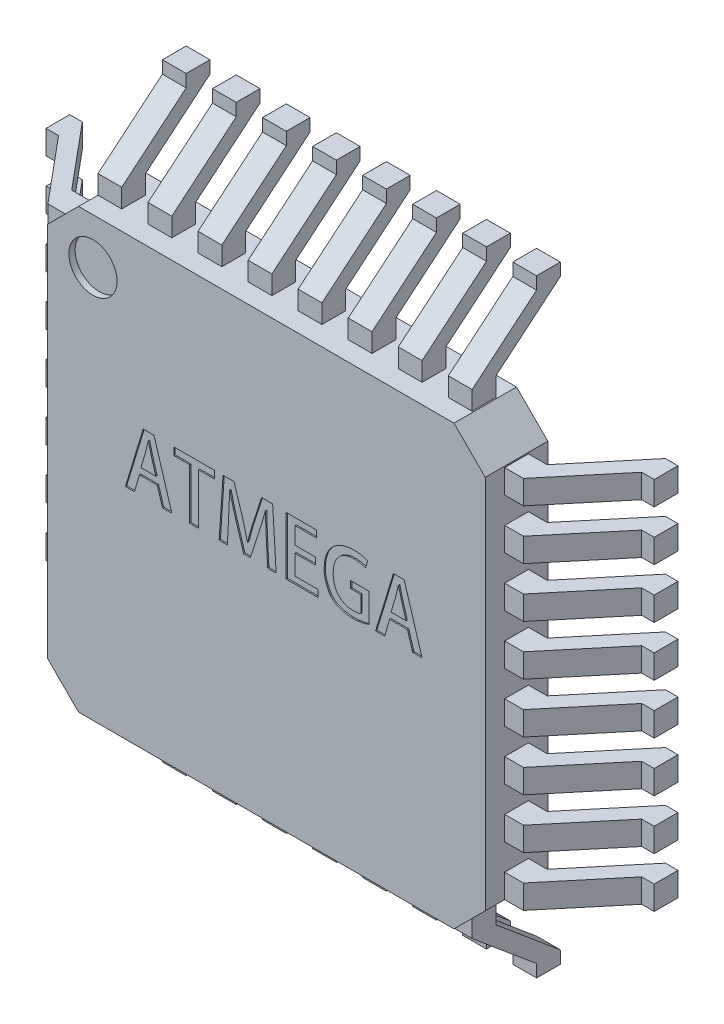
from build123d import *

# Parameters (mm, degrees)
CORPS_DEPTH                = 1
ESQUISSE2_R                = 0.385
ENL_V_MAT_EXTRU_1_DEPTH    = 0.1
TEXTE_DEPTH                = 0.02
PATTE_DEPTH                = 0.38
R_P_TITION_LIN_AIRE1_COUNT = 8
R_P_TITION_LIN_AIRE1_PITCH = 0.8
SYM_TRIE1_COPY_1_DEPTH     = 0.38
SYM_TRIE1_COPY_2_DEPTH     = 0.38
SYM_TRIE1_COPY_3_DEPTH     = 0.38
SYM_TRIE1_COPY_4_DEPTH     = 0.38
SYM_TRIE1_COPY_5_DEPTH     = 0.38
SYM_TRIE1_COPY_6_DEPTH     = 0.38
SYM_TRIE1_COPY_7_DEPTH     = 0.38
BOSS_EXTRU_3_DEPTH         = 0.38
R_P_TITION_LIN_AIRE2_COUNT = 8
R_P_TITION_LIN_AIRE2_PITCH = 0.8
SYM_TRIE2_COPY_1_DEPTH     = 0.38
SYM_TRIE2_COPY_2_DEPTH     = 0.38
SYM_TRIE2_COPY_3_DEPTH     = 0.38
SYM_TRIE2_COPY_4_DEPTH     = 0.38
SYM_TRIE2_COPY_5_DEPTH     = 0.38
SYM_TRIE2_COPY_6_DEPTH     = 0.38
SYM_TRIE2_COPY_7_DEPTH     = 0.38


with BuildPart() as part:
    # Esquisse1 → Corps (new body)
    with BuildSketch(Plane.XY):
        Polygon((-3.5, 3), (-3, 3.5), (3, 3.5), (3.5, 3), (3.5, -3), (3, -3.5), (-3, -3.5), (-3.5, -3), align=None)
    extrude(amount=CORPS_DEPTH)

    # Esquisse2 → Enlèv. mat.-Extru.1 (cut)
    with BuildSketch(Plane.XY.offset(1)):
        with Locations((-2.77, 2.77)):
            Circle(ESQUISSE2_R)
    extrude(amount=-ENL_V_MAT_EXTRU_1_DEPTH, mode=Mode.SUBTRACT)

    # Esquisse3 → Texte (cut)
    with BuildSketch(Plane.XY.offset(1)):
        Polygon((-1.793941796, 0.933727574), (-1.96665398, 0.933727574), (-2.251300977, -0.002415723), (-2.106526523, -0.002415723), (-2.026251846, 0.271286617), (-1.741641628, 0.271286617), (-1.657718102, -0.002415723), (-1.509331578, -0.002415723), align=None)
        with BuildLine():
            Line((-2.004358752, 0.381984009), (-1.93016549, 0.628287758))
            add(Edge.make_bspline(
                [(-1.93016549, 0.628287758), (-1.926197376, 0.643224093), (-1.918096873, 0.673715101), (-1.907409013, 0.720118537), (-1.896836875, 0.766426537), (-1.889875841, 0.79705332), (-1.886475719, 0.812012999)],
                knots=[0, 0, 0, 0, 0.981880665, 2.004409445, 3.025252049, 4, 4, 4, 4], degree=3))
            Line((-1.886475719, 0.812012999), (-1.883946737, 0.812082089))
            add(Edge.make_bspline(
                [(-1.883946737, 0.812082089), (-1.880536217, 0.797210544), (-1.87355085, 0.7667509), (-1.862387649, 0.720611295), (-1.850566242, 0.673771581), (-1.84211295, 0.642582439), (-1.837902769, 0.627048617)],
                knots=[0, 0, 0, 0, 0.960134074, 1.966530216, 2.987225846, 4, 4, 4, 4], degree=3))
            Line((-1.837902769, 0.627048617), (-1.764751004, 0.381984009))
            Line((-1.764751004, 0.381984009), (-2.004358752, 0.381984009))
        make_face(mode=Mode.SUBTRACT)
        Polygon((-0.830576068, 0.933119346), (-1.475875117, 0.933119346), (-1.475875117, 0.812690316), (-1.225285418, 0.812690316), (-1.225285418, 0.002531388), (-1.082382222, 0.002531388), (-1.082382222, 0.812690316), (-0.830576068, 0.812690316), align=None)
        with BuildLine():
            Line((0.101915973, 0.933254775), (-0.07372237, 0.933254775))
            Line((-0.07372237, 0.933254775), (-0.20817655, 0.523950717))
            add(Edge.make_bspline(
                [(-0.20817655, 0.523950717), (-0.216923095, 0.495636112), (-0.234043696, 0.440212731), (-0.257509501, 0.358258573), (-0.278299802, 0.279254), (-0.290701109, 0.227400793), (-0.296767564, 0.202035311)],
                knots=[0, 0, 0, 0, 1.06482216, 2.08429696, 3.06287894, 4, 4, 4, 4], degree=3))
            Line((-0.296767564, 0.202035311), (-0.300235268, 0.202035311))
            add(Edge.make_bspline(
                [(-0.300235268, 0.202035311), (-0.306193378, 0.22763716), (-0.318314696, 0.27972216), (-0.338726769, 0.358699618), (-0.360780386, 0.4400672), (-0.376915699, 0.494851427), (-0.385114016, 0.522687171)],
                knots=[0, 0, 0, 0, 0.950771496, 1.934271678, 2.950408035, 4, 4, 4, 4], degree=3))
            Line((-0.385114016, 0.522687171), (-0.515846476, 0.933254775))
            Line((-0.515846476, 0.933254775), (-0.690273521, 0.933254775))
            Line((-0.690273521, 0.933254775), (-0.753283064, 0.003452064))
            Line((-0.753283064, 0.003452064), (-0.622440781, 0.003452064))
            Line((-0.622440781, 0.003452064), (-0.6018487, 0.384941791))
            add(Edge.make_bspline(
                [(-0.6018487, 0.384941791), (-0.599990138, 0.418358369), (-0.596240056, 0.485784141), (-0.592590464, 0.570088522), (-0.589325026, 0.63724432), (-0.587742554, 0.686005099), (-0.585978722, 0.732985602), (-0.585347561, 0.763673488), (-0.585037459, 0.778751089)],
                knots=[0, 0, 0, 0, 1.528265809, 3.083634274, 3.853229214, 4.59840858, 5.311368824, 6, 6, 6, 6], degree=3))
            Line((-0.585037459, 0.778751089), (-0.581256618, 0.77876501))
            add(Edge.make_bspline(
                [(-0.581256618, 0.77876501), (-0.575058103, 0.749976707), (-0.562483141, 0.691573714), (-0.540223211, 0.603511662), (-0.515759508, 0.513490364), (-0.497378224, 0.453242707), (-0.488067549, 0.42272545)],
                knots=[0, 0, 0, 0, 0.959753872, 1.947058171, 2.960122984, 4, 4, 4, 4], degree=3))
            Line((-0.488067549, 0.42272545), (-0.360800214, 0.011967248))
            Line((-0.360800214, 0.011967248), (-0.255417208, 0.011967248))
            Line((-0.255417208, 0.011967248), (-0.117329131, 0.4312781))
            add(Edge.make_bspline(
                [(-0.117329131, 0.4312781), (-0.107638921, 0.460951989), (-0.088449253, 0.519715632), (-0.061823314, 0.607423424), (-0.037069687, 0.693538588), (-0.021952565, 0.75056645), (-0.014481294, 0.778751089)],
                knots=[0, 0, 0, 0, 1.033513873, 2.046682856, 3.034620343, 4, 4, 4, 4], degree=3))
            Line((-0.014481294, 0.778751089), (-0.010734826, 0.77876501))
            add(Edge.make_bspline(
                [(-0.010734826, 0.77876501), (-0.010792976, 0.76380115), (-0.010911541, 0.73329045), (-0.010307773, 0.686763744), (-0.009329318, 0.638653404), (-0.006831596, 0.572835057), (-0.003336125, 0.490470756), (-0.000195811, 0.424660087), (0.001357711, 0.392103373)],
                knots=[0, 0, 0, 0, 0.69615936, 1.419440619, 2.164688967, 2.934803833, 4.483639269, 6, 6, 6, 6], degree=3))
            Line((0.001357711, 0.392103373), (0.021970245, 0.003452064))
            Line((0.021970245, 0.003452064), (0.157635724, 0.003452064))
            Line((0.157635724, 0.003452064), (0.101915973, 0.933254775))
        make_face()
        Polygon((0.826841771, 0.111665158), (0.460688862, 0.111665158), (0.460688862, 0.428972714), (0.786698761, 0.428972714), (0.786698761, 0.539670105), (0.460688862, 0.539670105), (0.460688862, 0.811924489), (0.806162038, 0.811924489), (0.806162038, 0.92262188), (0.317785665, 0.92262188), (0.317785665, 0.000967767), (0.826841771, 0.000967767), align=None)
        with BuildLine():
            Line((1.644390344, 0.494616934), (1.347298832, 0.494616934))
            Line((1.347298832, 0.494616934), (1.347298832, 0.383919543))
            Line((1.347298832, 0.383919543), (1.510638573, 0.383919543))
            Line((1.510638573, 0.383919543), (1.510638573, 0.119955888))
            add(Edge.make_bspline(
                [(1.510638573, 0.119955888), (1.507621633, 0.118432672), (1.501122065, 0.11515112), (1.489931858, 0.111657251), (1.476986764, 0.108530537), (1.462206798, 0.105644928), (1.445429104, 0.103727938), (1.426785447, 0.101840673), (1.406166186, 0.100940433), (1.391787843, 0.100528716), (1.384278853, 0.1003137)],
                knots=[0, 0, 0, 0, 0.628657126, 1.35435217, 2.175978514, 3.110421812, 4.156817278, 5.320312974, 6.600551933, 8, 8, 8, 8], degree=3))
            add(Edge.make_bspline(
                [(1.384278853, 0.1003137), (1.372765759, 0.100627352), (1.350240327, 0.101241015), (1.317310135, 0.105771078), (1.286096084, 0.112868404), (1.256624533, 0.123013479), (1.228889345, 0.135808659), (1.20298304, 0.151674766), (1.178779887, 0.170230122), (1.15633572, 0.191524209), (1.136235167, 0.21576654), (1.118564195, 0.24266281), (1.103507508, 0.272210601), (1.091538978, 0.304541546), (1.081511848, 0.339315972), (1.074697882, 0.37687837), (1.070241621, 0.416991152), (1.06936031, 0.444594524), (1.068906661, 0.458803184)],
                knots=[0, 0, 0, 0, 1.023380374, 2.002249163, 2.949895749, 3.865344944, 4.768422331, 5.660268692, 6.560570344, 7.475499333, 8.405103518, 9.354098415, 10.331479191, 11.346692462, 12.414919926, 13.545312504, 14.736465237, 16, 16, 16, 16], degree=3))
            add(Edge.make_bspline(
                [(1.068906661, 0.458803184), (1.069411211, 0.47342277), (1.07039251, 0.501856367), (1.075116841, 0.543056768), (1.082643333, 0.581510717), (1.092969324, 0.617186116), (1.106139277, 0.65014461), (1.122296013, 0.680233351), (1.140883072, 0.707756677), (1.162554953, 0.732087377), (1.186371049, 0.753564512), (1.212013306, 0.772341615), (1.239487826, 0.78830168), (1.268754446, 0.801324523), (1.299851574, 0.811413624), (1.332633086, 0.818512804), (1.367195762, 0.823102027), (1.390834025, 0.823566507), (1.402933682, 0.823804259)],
                knots=[0, 0, 0, 0, 1.253625744, 2.438173572, 3.550642562, 4.608904388, 5.61744, 6.587113079, 7.531417707, 8.457701223, 9.3727365, 10.275977657, 11.177312944, 12.091283575, 13.016829659, 13.974642132, 14.963285266, 16, 16, 16, 16], degree=3))
            add(Edge.make_bspline(
                [(1.402933682, 0.823804259), (1.413263485, 0.82369085), (1.43312499, 0.823472794), (1.461594824, 0.821226326), (1.487665364, 0.818259356), (1.511318623, 0.813608372), (1.532971412, 0.807982108), (1.553003616, 0.802246625), (1.571268618, 0.795258373), (1.58270115, 0.790069168), (1.588250042, 0.787550536)],
                knots=[0, 0, 0, 0, 1.30171198, 2.502851171, 3.597914207, 4.607213195, 5.537970003, 6.417597932, 7.231965557, 8, 8, 8, 8], degree=3))
            Line((1.588250042, 0.787550536), (1.619310373, 0.905048594))
            add(Edge.make_bspline(
                [(1.619310373, 0.905048594), (1.613105117, 0.907926886), (1.600062684, 0.913976586), (1.578628903, 0.921418558), (1.554637523, 0.928054791), (1.528156259, 0.933854115), (1.499467143, 0.938309671), (1.46887293, 0.941632671), (1.436520242, 0.943811026), (1.414317928, 0.944055397), (1.402933682, 0.944180698)],
                knots=[0, 0, 0, 0, 0.740407202, 1.556214791, 2.453313001, 3.435254213, 4.490154834, 5.595828713, 6.767260142, 8, 8, 8, 8], degree=3))
            add(Edge.make_bspline(
                [(1.402933682, 0.944180698), (1.385373187, 0.943655586), (1.351076286, 0.942630004), (1.301033426, 0.936144509), (1.253634208, 0.926058278), (1.208903673, 0.911823674), (1.166955145, 0.893388954), (1.127680858, 0.871177781), (1.091164967, 0.844914343), (1.057517371, 0.814837733), (1.027252951, 0.781010731), (1.000617393, 0.743847838), (0.978269168, 0.703250716), (0.95970325, 0.659496384), (0.945136946, 0.612430552), (0.934472606, 0.562132489), (0.927724585, 0.508549244), (0.926471289, 0.471728949), (0.925827647, 0.452819559)],
                knots=[0, 0, 0, 0, 1.090315603, 2.129464252, 3.128267071, 4.095910946, 5.038656024, 5.968469917, 6.892414709, 7.826229779, 8.765188392, 9.705220327, 10.659053819, 11.636683231, 12.651674346, 13.713313579, 14.8256519, 16, 16, 16, 16], degree=3))
            add(Edge.make_bspline(
                [(0.925827647, 0.452819559), (0.925348782, 0.442202739), (0.92437187, 0.420543855), (0.926423099, 0.387361024), (0.931694144, 0.353094238), (0.939669646, 0.317708229), (0.950393453, 0.28114658), (0.964508661, 0.243641197), (0.981290162, 0.204934393), (0.997195809, 0.172163278), (1.012113929, 0.146246062), (1.025173718, 0.127740838), (1.039892582, 0.110365707), (1.056270778, 0.094178284), (1.074345589, 0.079188908), (1.093981461, 0.065234079), (1.115220424, 0.052352224), (1.138312602, 0.041031817), (1.162731855, 0.030379579), (1.188853432, 0.021093204), (1.216608107, 0.013016053), (1.245986188, 0.006033551), (1.277032137, 2.661e-06), (1.309693014, -0.004669814), (1.343983379, -0.008206416), (1.367377415, -0.009646348), (1.379351163, -0.010383348)],
                knots=[0, 0, 0, 0, 1.037395396, 2.116342319, 3.240172524, 4.420265276, 5.656648825, 6.958217321, 8.331154295, 9.776251068, 10.513215637, 11.249177366, 11.984960669, 12.734446063, 13.495146977, 14.275718104, 15.085352838, 15.918071806, 16.785466737, 17.686130797, 18.623441817, 19.607294607, 20.634291141, 21.711106358, 22.828477673, 24, 24, 24, 24], degree=3))
            add(Edge.make_bspline(
                [(1.379351163, -0.010383348), (1.393318749, -0.010038386), (1.420579636, -0.009365114), (1.460445951, -0.006295084), (1.498357735, -0.001871536), (1.533947026, 0.004543535), (1.566659087, 0.011713042), (1.59599104, 0.01901406), (1.621489301, 0.026644795), (1.637022904, 0.032370814), (1.644214527, 0.0350218)],
                knots=[0, 0, 0, 0, 1.241655218, 2.423369539, 3.552567028, 4.632677634, 5.635967409, 6.528781088, 7.318866879, 8, 8, 8, 8], degree=3))
            Line((1.644214527, 0.0350218), (1.644390344, 0.494616934))
        make_face()
        Polygon((2.20452707, 0.933727574), (2.031814886, 0.933727574), (1.747167889, -0.002415723), (1.891942343, -0.002415723), (1.97221702, 0.271286617), (2.256827238, 0.271286617), (2.340750764, -0.002415723), (2.489137288, -0.002415723), align=None)
        with BuildLine():
            Line((1.994110114, 0.381984009), (2.068303376, 0.628287758))
            add(Edge.make_bspline(
                [(2.068303376, 0.628287758), (2.07227149, 0.643224093), (2.080371992, 0.673715101), (2.091059853, 0.720118537), (2.101631991, 0.766426537), (2.108593024, 0.79705332), (2.111993147, 0.812012999)],
                knots=[0, 0, 0, 0, 0.981880665, 2.004409445, 3.025252049, 4, 4, 4, 4], degree=3))
            Line((2.111993147, 0.812012999), (2.114522129, 0.812082089))
            add(Edge.make_bspline(
                [(2.114522129, 0.812082089), (2.117932648, 0.797210544), (2.124918016, 0.7667509), (2.136081216, 0.720611295), (2.147902624, 0.673771581), (2.156355916, 0.642582439), (2.160566096, 0.627048617)],
                knots=[0, 0, 0, 0, 0.960134074, 1.966530216, 2.987225846, 4, 4, 4, 4], degree=3))
            Line((2.160566096, 0.627048617), (2.233717861, 0.381984009))
            Line((2.233717861, 0.381984009), (1.994110114, 0.381984009))
        make_face(mode=Mode.SUBTRACT)
    extrude(amount=-TEXTE_DEPTH, mode=Mode.SUBTRACT)

    # Esquisse5 → Patte (add)
    with BuildSketch(Plane(origin=(0, -3, 0), x_dir=(-1, 0, 0), z_dir=(0, -1, 0))):
        Polygon((3.5, -0.69), (3.8, -0.69), (4.66, 0.34), (4.86, 0.34), (4.86, 0.72), (4.66, 0.72), (3.8, -0.31), (3.5, -0.31), align=None)
    patte = extrude(amount=-PATTE_DEPTH)

    # Répétition linéaire1: Patte ×8
    with Locations(*[(0, i * R_P_TITION_LIN_AIRE1_PITCH, 0) for i in range(1, R_P_TITION_LIN_AIRE1_COUNT)]):
        add(patte)

    # Symétrie1: Patte across plane
    add(patte.mirror(Plane(origin=(0, 0, 0), x_dir=(0, 0, 1), z_dir=(1, 0, 0))))

    # Symétrie1 copy 1 sketch → Symétrie1 copy 1 (add)
    with BuildSketch(Plane.XZ.offset(2.2)):
        Polygon((3.5, 0.69), (3.8, 0.69), (4.66, -0.34), (4.86, -0.34), (4.86, -0.72), (4.66, -0.72), (3.8, 0.31), (3.5, 0.31), align=None)
    extrude(amount=-SYM_TRIE1_COPY_1_DEPTH)

    # Symétrie1 copy 2 sketch → Symétrie1 copy 2 (add)
    with BuildSketch(Plane.XZ.offset(1.4)):
        Polygon((3.5, 0.69), (3.8, 0.69), (4.66, -0.34), (4.86, -0.34), (4.86, -0.72), (4.66, -0.72), (3.8, 0.31), (3.5, 0.31), align=None)
    extrude(amount=-SYM_TRIE1_COPY_2_DEPTH)

    # Symétrie1 copy 3 sketch → Symétrie1 copy 3 (add)
    with BuildSketch(Plane.XZ.offset(0.6)):
        Polygon((3.5, 0.69), (3.8, 0.69), (4.66, -0.34), (4.86, -0.34), (4.86, -0.72), (4.66, -0.72), (3.8, 0.31), (3.5, 0.31), align=None)
    extrude(amount=-SYM_TRIE1_COPY_3_DEPTH)

    # Symétrie1 copy 4 sketch → Symétrie1 copy 4 (add)
    with BuildSketch(Plane.XZ.offset(-0.2)):
        Polygon((3.5, 0.69), (3.8, 0.69), (4.66, -0.34), (4.86, -0.34), (4.86, -0.72), (4.66, -0.72), (3.8, 0.31), (3.5, 0.31), align=None)
    extrude(amount=-SYM_TRIE1_COPY_4_DEPTH)

    # Symétrie1 copy 5 sketch → Symétrie1 copy 5 (add)
    with BuildSketch(Plane.XZ.offset(-1)):
        Polygon((3.5, 0.69), (3.8, 0.69), (4.66, -0.34), (4.86, -0.34), (4.86, -0.72), (4.66, -0.72), (3.8, 0.31), (3.5, 0.31), align=None)
    extrude(amount=-SYM_TRIE1_COPY_5_DEPTH)

    # Symétrie1 copy 6 sketch → Symétrie1 copy 6 (add)
    with BuildSketch(Plane.XZ.offset(-1.8)):
        Polygon((3.5, 0.69), (3.8, 0.69), (4.66, -0.34), (4.86, -0.34), (4.86, -0.72), (4.66, -0.72), (3.8, 0.31), (3.5, 0.31), align=None)
    extrude(amount=-SYM_TRIE1_COPY_6_DEPTH)

    # Symétrie1 copy 7 sketch → Symétrie1 copy 7 (add)
    with BuildSketch(Plane.XZ.offset(-2.6)):
        Polygon((3.5, 0.69), (3.8, 0.69), (4.66, -0.34), (4.86, -0.34), (4.86, -0.72), (4.66, -0.72), (3.8, 0.31), (3.5, 0.31), align=None)
    extrude(amount=-SYM_TRIE1_COPY_7_DEPTH)

    # Esquisse6 → Boss.-Extru.3 (add)
    with BuildSketch(Plane.ZY.offset(3)):
        Polygon((0.69, -3.5), (0.69, -3.8), (-0.34, -4.66), (-0.34, -4.86), (-0.72, -4.86), (-0.72, -4.66), (0.31, -3.8), (0.31, -3.5), align=None)
    boss_extru_3 = extrude(amount=-BOSS_EXTRU_3_DEPTH)

    # Répétition linéaire2: Boss.-Extru.3 ×8
    with Locations(*[(i * R_P_TITION_LIN_AIRE2_PITCH, 0, 0) for i in range(1, R_P_TITION_LIN_AIRE2_COUNT)]):
        add(boss_extru_3)

    # Symétrie2: Boss.-Extru.3 across plane
    add(boss_extru_3.mirror(Plane.ZX))

    # Symétrie2 copy 1 sketch → Symétrie2 copy 1 (add)
    with BuildSketch(Plane.ZY.offset(2.2)):
        Polygon((0.69, 3.5), (0.69, 3.8), (-0.34, 4.66), (-0.34, 4.86), (-0.72, 4.86), (-0.72, 4.66), (0.31, 3.8), (0.31, 3.5), align=None)
    extrude(amount=-SYM_TRIE2_COPY_1_DEPTH)

    # Symétrie2 copy 2 sketch → Symétrie2 copy 2 (add)
    with BuildSketch(Plane.ZY.offset(1.4)):
        Polygon((0.69, 3.5), (0.69, 3.8), (-0.34, 4.66), (-0.34, 4.86), (-0.72, 4.86), (-0.72, 4.66), (0.31, 3.8), (0.31, 3.5), align=None)
    extrude(amount=-SYM_TRIE2_COPY_2_DEPTH)

    # Symétrie2 copy 3 sketch → Symétrie2 copy 3 (add)
    with BuildSketch(Plane.ZY.offset(0.6)):
        Polygon((0.69, 3.5), (0.69, 3.8), (-0.34, 4.66), (-0.34, 4.86), (-0.72, 4.86), (-0.72, 4.66), (0.31, 3.8), (0.31, 3.5), align=None)
    extrude(amount=-SYM_TRIE2_COPY_3_DEPTH)

    # Symétrie2 copy 4 sketch → Symétrie2 copy 4 (add)
    with BuildSketch(Plane.ZY.offset(-0.2)):
        Polygon((0.69, 3.5), (0.69, 3.8), (-0.34, 4.66), (-0.34, 4.86), (-0.72, 4.86), (-0.72, 4.66), (0.31, 3.8), (0.31, 3.5), align=None)
    extrude(amount=-SYM_TRIE2_COPY_4_DEPTH)

    # Symétrie2 copy 5 sketch → Symétrie2 copy 5 (add)
    with BuildSketch(Plane.ZY.offset(-1)):
        Polygon((0.69, 3.5), (0.69, 3.8), (-0.34, 4.66), (-0.34, 4.86), (-0.72, 4.86), (-0.72, 4.66), (0.31, 3.8), (0.31, 3.5), align=None)
    extrude(amount=-SYM_TRIE2_COPY_5_DEPTH)

    # Symétrie2 copy 6 sketch → Symétrie2 copy 6 (add)
    with BuildSketch(Plane.ZY.offset(-1.8)):
        Polygon((0.69, 3.5), (0.69, 3.8), (-0.34, 4.66), (-0.34, 4.86), (-0.72, 4.86), (-0.72, 4.66), (0.31, 3.8), (0.31, 3.5), align=None)
    extrude(amount=-SYM_TRIE2_COPY_6_DEPTH)

    # Symétrie2 copy 7 sketch → Symétrie2 copy 7 (add)
    with BuildSketch(Plane.ZY.offset(-2.6)):
        Polygon((0.69, 3.5), (0.69, 3.8), (-0.34, 4.66), (-0.34, 4.86), (-0.72, 4.86), (-0.72, 4.66), (0.31, 3.8), (0.31, 3.5), align=None)
    extrude(amount=-SYM_TRIE2_COPY_7_DEPTH)


solid = part.part
